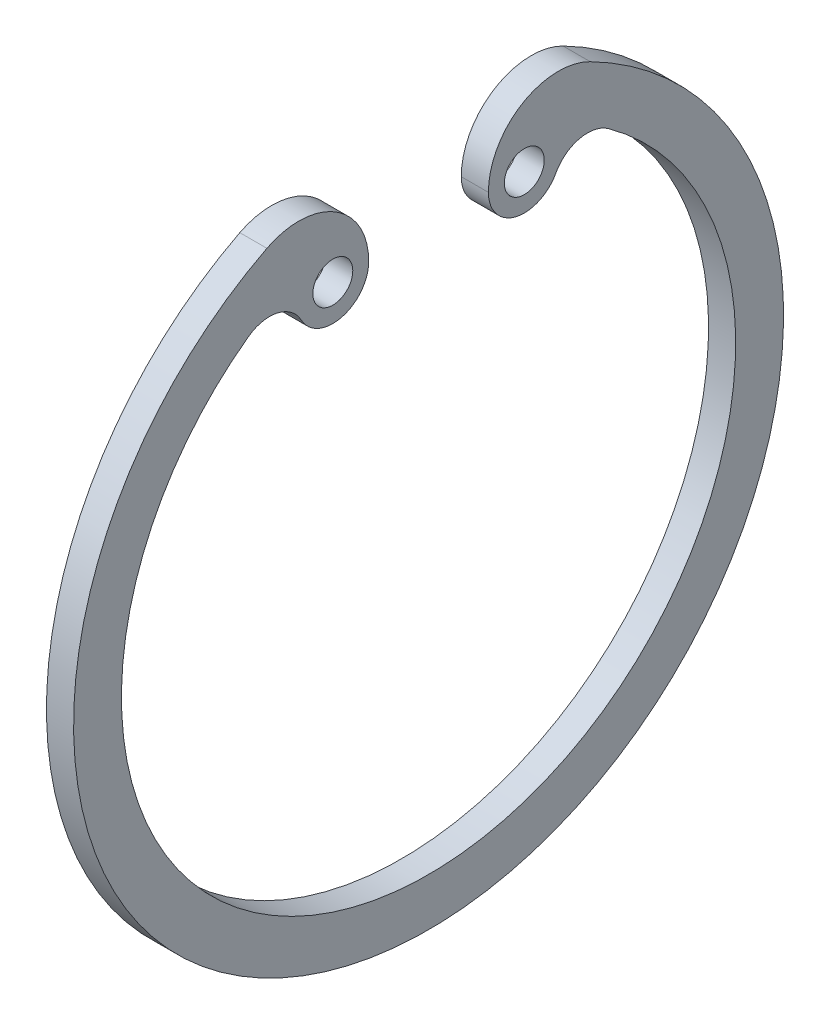
from build123d import *

# Parameters (mm, degrees)
SKETCH_1_R      = 1.25
EXTRUDE_1_DEPTH = 1.7


with BuildPart() as part:
    # Эскиз1 → Бобышка-Вытянуть1 (new body)
    with BuildSketch(Plane(origin=(0, 0, 0), x_dir=(0, 0, -1), z_dir=(1, 0, 0))):
        with BuildLine():
            ThreePointArc((-10.131054898, 19.809700317), (0, -22.25), (10.131054898, 19.809700317))
            ThreePointArc((10.131054898, 19.809700317), (5.846468463, 19.646192396), (3.75, 15.905973721))
            ThreePointArc((3.75, 15.905973721), (5.450478118, 13.724110823), (7.981578402, 14.840212472))
            ThreePointArc((7.981578402, 14.840212472), (9.459913455, 15.96745057), (11.281809909, 15.597540356))
            ThreePointArc((11.281809909, 15.597540356), (0, -19.25), (-11.281809909, 15.597540356))
            ThreePointArc((-11.281809909, 15.597540356), (-9.459913455, 15.96745057), (-7.981578402, 14.840212472))
            ThreePointArc((-7.981578402, 14.840212472), (-5.450478118, 13.724110823), (-3.75, 15.905973721))
            ThreePointArc((-3.75, 15.905973721), (-5.846468463, 19.646192396), (-10.131054898, 19.809700317))
        make_face()
        with Locations((-6, 15.905973721)):
            Circle(SKETCH_1_R, mode=Mode.SUBTRACT)
        with Locations((6, 15.905973721)):
            Circle(SKETCH_1_R, mode=Mode.SUBTRACT)
    extrude(amount=EXTRUDE_1_DEPTH)


solid = part.part
